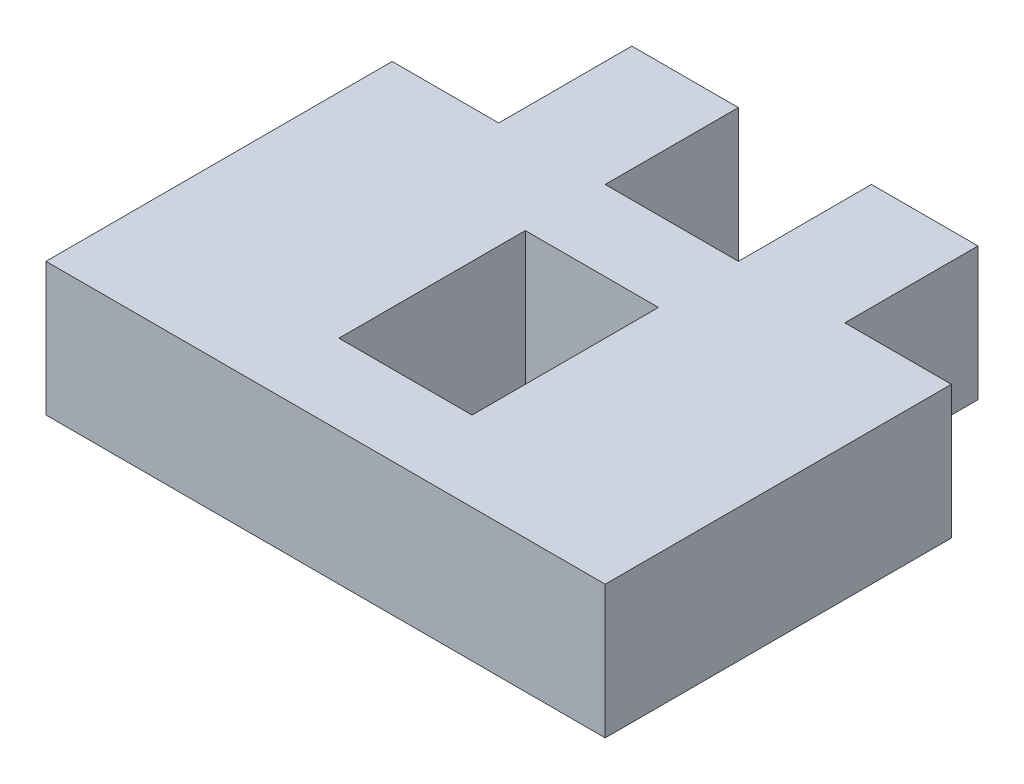
from build123d import *

# Parameters (mm, degrees)
SALIENTE_EXTRUIR1_DEPTH = 5
CROQUIS2_W              = 5
CROQUIS2_H              = 7
CORTAR_EXTRUIR1_DEPTH   = 5


with BuildPart() as part:
    # Croquis1 → Saliente-Extruir1 (new body)
    with BuildSketch(Plane(origin=(0, 0, 0), x_dir=(1, 0, 0), z_dir=(0, 1, 0))):
        Polygon((-6.090909091, 11.954545455), (-10.090909091, 11.954545455), (-10.090909091, 6.954545455), (-14.090909091, 6.954545455), (-14.090909091, -6.045454545), (6.909090909, -6.045454545), (6.909090909, 6.954545455), (2.909090909, 6.954545455), (2.909090909, 11.954545455), (-1.090909091, 11.954545455), (-1.090909091, 6.954545455), (-6.090909091, 6.954545455), align=None)
    extrude(amount=SALIENTE_EXTRUIR1_DEPTH)

    # Croquis2 → Cortar-Extruir1 (cut)
    with BuildSketch(Plane(origin=(0, 5, 0), x_dir=(1, 0, 0), z_dir=(0, 1, 0))):
        with Locations((-3.590909091, 0.454545455)):
            Rectangle(CROQUIS2_W, CROQUIS2_H)
    extrude(amount=-CORTAR_EXTRUIR1_DEPTH, mode=Mode.SUBTRACT)


solid = part.part
